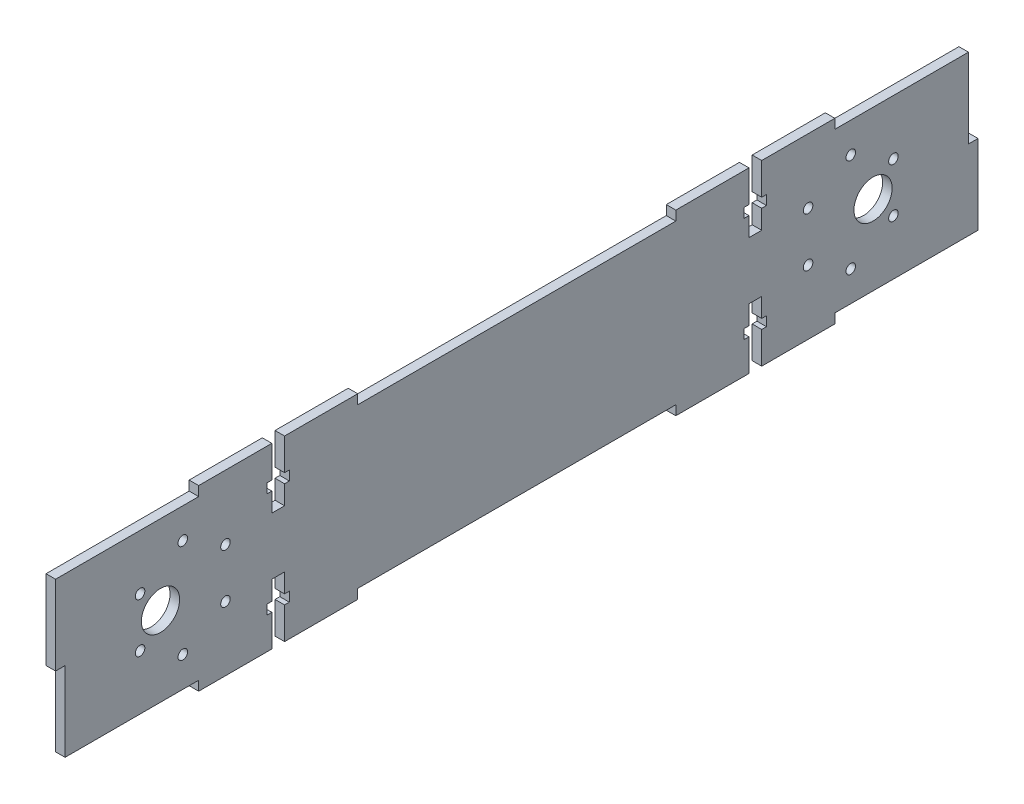
from build123d import *

# Parameters (mm, degrees)
SKETCH1_R           = 6
SKETCH1_R_2         = 1.5
BOSS_EXTRUDE1_DEPTH = 3
CUT_EXTRUDE1_DEPTH  = 3


with BuildPart() as part:
    # Sketch1 → Boss-Extrude1 (new body)
    with BuildSketch(Plane(origin=(0, 0, 0), x_dir=(0, 0, -1), z_dir=(1, 0, 0))):
        Polygon((-145, 0), (-142, 0), (-142, -25), (-100, -25), (-100, -28), (-50, -28), (-50, -25), (50, -25), (50, -28), (100, -28), (100, -25), (145, -25), (145, 0), (142, 0), (142, 25), (100, 25), (100, 28), (50, 28), (50, 25), (-50, 25), (-50, 28), (-100, 28), (-100, 25), (-145, 25), align=None)
        with Locations((-112, 0)):
            Circle(SKETCH1_R, mode=Mode.SUBTRACT)
        with Locations((112, 0)):
            Circle(SKETCH1_R, mode=Mode.SUBTRACT)
        with Locations((-105, 15.5)):
            Circle(SKETCH1_R_2, mode=Mode.SUBTRACT)
        with Locations((-91.576606241, 7.75)):
            Circle(SKETCH1_R_2, mode=Mode.SUBTRACT)
        with Locations((-91.576606241, -7.75)):
            Circle(SKETCH1_R_2, mode=Mode.SUBTRACT)
        with Locations((-105, -15.5)):
            Circle(SKETCH1_R_2, mode=Mode.SUBTRACT)
        with Locations((-118.423393759, -7.75)):
            Circle(SKETCH1_R_2, mode=Mode.SUBTRACT)
        with Locations((-118.423393759, 7.75)):
            Circle(SKETCH1_R_2, mode=Mode.SUBTRACT)
        with Locations((118.423393759, -7.75)):
            Circle(SKETCH1_R_2, mode=Mode.SUBTRACT)
        with Locations((105, -15.5)):
            Circle(SKETCH1_R_2, mode=Mode.SUBTRACT)
        with Locations((91.576606241, -7.75)):
            Circle(SKETCH1_R_2, mode=Mode.SUBTRACT)
        with Locations((91.576606241, 7.75)):
            Circle(SKETCH1_R_2, mode=Mode.SUBTRACT)
        with Locations((105, 15.5)):
            Circle(SKETCH1_R_2, mode=Mode.SUBTRACT)
        with Locations((118.423393759, 7.75)):
            Circle(SKETCH1_R_2, mode=Mode.SUBTRACT)
    extrude(amount=BOSS_EXTRUDE1_DEPTH)

    # Sketch2 → Cut-Extrude1 (cut)
    with BuildSketch(Plane(origin=(3, 0, 0), x_dir=(0, 0, -1), z_dir=(1, 0, 0))):
        Polygon((-75, 28), (-73, 28), (-73, 18), (-71.5, 18), (-71.5, 15), (-73, 15), (-73, 9), (-77, 9), (-77, 15), (-78.5, 15), (-78.5, 18), (-77, 18), (-77, 28), align=None)
        Polygon((-73, -28), (-73, -18), (-71.5, -18), (-71.5, -15), (-73, -15), (-73, -9), (-77, -9), (-77, -15), (-78.5, -15), (-78.5, -18), (-77, -18), (-77, -28), align=None)
        Polygon((75, -28), (77, -28), (77, -18), (78.5, -18), (78.5, -15), (77, -15), (77, -9), (73, -9), (73, -15), (71.5, -15), (71.5, -18), (73, -18), (73, -28), align=None)
        Polygon((77, 28), (77, 18), (78.5, 18), (78.5, 15), (77, 15), (77, 9), (73, 9), (73, 15), (71.5, 15), (71.5, 18), (73, 18), (73, 28), align=None)
    extrude(amount=-CUT_EXTRUDE1_DEPTH, mode=Mode.SUBTRACT)


solid = part.part
